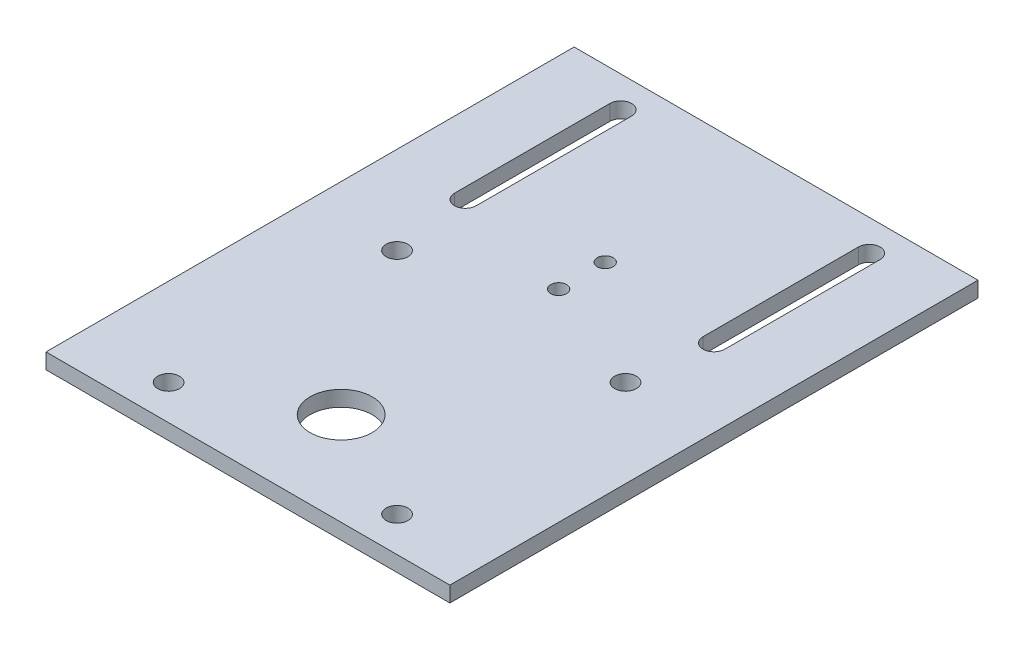
from build123d import *

# Parameters (mm, degrees)
SKETCH_3_W          = 130
SKETCH_3_H          = 170
EXTRUDE_1_DEPTH     = 5
SKETCH_4_R          = 10
CUT_EXTRUDE_1_DEPTH = 10
SKETCH_5_R          = 3.5
SKETCH_5_R_2        = 2.55
CUT_EXTRUDE_2_DEPTH = 10


with BuildPart() as part:
    # 草图3 → 凸台-拉伸1 (new body)
    with BuildSketch(Plane(origin=(0, 0, 0), x_dir=(1, 0, 0), z_dir=(0, 1, 0))):
        Rectangle(SKETCH_3_W, SKETCH_3_H)
    extrude(amount=EXTRUDE_1_DEPTH)

    # 草图4 → 切除-拉伸1 (cut)
    with BuildSketch(Plane.XZ):
        with Locations((0, 55)):
            Circle(SKETCH_4_R)
    extrude(amount=-CUT_EXTRUDE_1_DEPTH, mode=Mode.SUBTRACT)

    # 草图5 → 切除-拉伸2 (cut)
    with BuildSketch(Plane.XZ):
        with Locations((36.769552622, 0.230447378)):
            Circle(SKETCH_5_R)
        with Locations((-36.769552622, 0.230447378)):
            Circle(SKETCH_5_R)
        with Locations((-36.769552622, 73.769552622)):
            Circle(SKETCH_5_R)
        with Locations((36.769552622, 73.769552622)):
            Circle(SKETCH_5_R)
        with Locations((0, -30)):
            Circle(SKETCH_5_R_2)
        with Locations((0, -15)):
            Circle(SKETCH_5_R_2)
        with BuildLine():
            Line((36.5, -75), (36.5, -25))
            ThreePointArc((36.5, -25), (40, -21.5), (43.5, -25))
            Line((43.5, -25), (43.5, -75))
            ThreePointArc((43.5, -75), (40, -78.5), (36.5, -75))
        make_face()
        with BuildLine():
            Line((-36.5, -75), (-36.5, -25))
            ThreePointArc((-36.5, -25), (-40, -21.5), (-43.5, -25))
            Line((-43.5, -25), (-43.5, -75))
            ThreePointArc((-43.5, -75), (-40, -78.5), (-36.5, -75))
        make_face()
    extrude(amount=-CUT_EXTRUDE_2_DEPTH, mode=Mode.SUBTRACT)


solid = part.part
